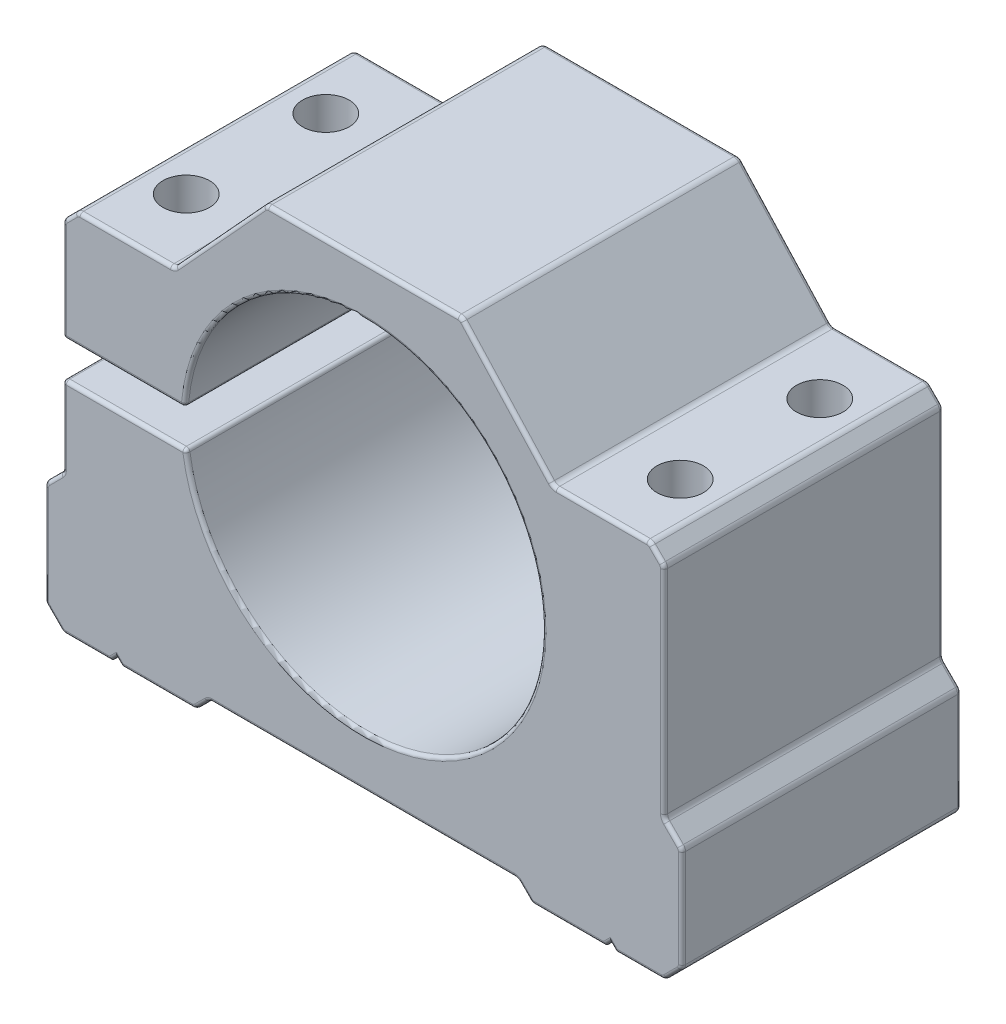
from build123d import *

# Parameters (mm, degrees)
EXTRUDE_1_DEPTH     = 19.5
SKETCH_2_R          = 3.25
CUT_EXTRUDE_1_DEPTH = 72.165300533
FILLET_1_R          = 1
FILLET_2_R          = 0.5


with BuildPart() as part:
    # Эскиз1 → Бобышка-Вытянуть1 (new, symmetric)
    with BuildSketch(Plane.XY):
        with BuildLine():
            Line((-21.5, -32), (21.5, -32))
            Line((21.5, -32), (23.5, -34))
            Line((23.5, -34), (33.75, -34))
            Line((33.75, -34), (34.5, -33.25))
            Line((34.5, -33.25), (35.25, -34))
            Line((35.25, -34), (42, -34))
            Line((42, -34), (44.5, -31.5))
            Line((44.5, -31.5), (44.5, -17))
            Line((44.5, -17), (42, -14.5))
            Line((42, -14.5), (42, 16))
            Line((42, 16), (40, 18))
            Line((40, 18), (26.5, 18))
            Line((26.5, 18), (13.671363564, 32))
            Line((13.671363564, 32), (-13.671363564, 32))
            Line((-13.671363564, 32), (-26.5, 18))
            Line((-26.5, 18), (-40, 18))
            Line((-40, 18), (-42, 16))
            Line((-42, 16), (-42, 1.75))
            Line((-42, 1.75), (-24.938674784, 1.75))
            ThreePointArc((-24.938674784, 1.75), (0.87553709, 24.984663992), (25, 0))
            ThreePointArc((25, 0), (1.62845845, -24.946906082), (-24.787849846, -3.25))
            Line((-24.787849846, -3.25), (-42, -3.25))
            Line((-42, -3.25), (-42, -14.5))
            Line((-42, -14.5), (-44.5, -17))
            Line((-44.5, -17), (-44.5, -31.5))
            Line((-44.5, -31.5), (-42, -34))
            Line((-42, -34), (-35.25, -34))
            Line((-35.25, -34), (-34.5, -33.25))
            Line((-34.5, -33.25), (-33.75, -34))
            Line((-33.75, -34), (-23.5, -34))
            Line((-23.5, -34), (-21.5, -32))
        make_face()
    extrude(amount=EXTRUDE_1_DEPTH, both=True)

    # Эскиз2 → Вырез-Вытянуть1 (cut, through all)
    with BuildSketch(Plane(origin=(0, 18, 0), x_dir=(1, 0, 0), z_dir=(0, 1, 0))):
        with Locations(Location((-34.5, -9.75, 0), (0, 0, 270))):
            Circle(SKETCH_2_R)
        with Locations(Location((-34.5, 9.75, 0), (0, 0, 270))):
            Circle(SKETCH_2_R)
        with Locations(Location((34.5, -9.75, 0), (0, 0, 270))):
            Circle(SKETCH_2_R)
        with Locations(Location((34.5, 9.75, 0), (0, 0, 270))):
            Circle(SKETCH_2_R)
    extrude(amount=-CUT_EXTRUDE_1_DEPTH, mode=Mode.SUBTRACT)

    # Скругление1
    fillet_1_edges = [part.edges().sort_by_distance(p)[0] for p in [
        (-42, 16, -9.75),
        (-40, 18, -9.75),
        (-26.5, 18, -9.75),
        (-13.671363564, 32, -9.75),
        (13.671363564, 32, -9.75),
        (26.5, 18, -9.75),
        (40, 18, -9.75),
        (42, 16, -9.75),
        (42, -14.5, -9.75),
        (44.5, -17, -9.75),
        (44.5, -31.5, -9.75),
        (42, -34, -9.75),
        (23.5, -34, -9.75),
        (21.5, -32, -9.75),
        (-21.5, -32, -9.75),
        (-23.5, -34, -9.75),
        (-42, -34, -9.75),
        (-44.5, -31.5, -9.75),
        (-44.5, -17, -9.75),
        (-42, -14.5, -9.75),
    ]]
    fillet(fillet_1_edges, radius=FILLET_1_R)

    # Скругление2
    fillet_2_edges = [part.edges().sort_by_distance(p)[0] for p in [
        (-42, 8.667893219, 19.5),
        (-33.469337392, 1.75, 19.5),
        (-41, 17, -19.5),
        (-33.262898484, 18, -19.5),
        (-20.085681782, 25, -19.5),
        (0, 32, -19.5),
        (20.085681782, 25, -19.5),
        (33.262898484, 18, -19.5),
        (41, 17, -19.5),
        (42, 0.75, -19.5),
        (43.25, -15.75, -19.5),
        (44.5, -24.25, -19.5),
        (43.25, -32.75, -19.5),
        (28.832106781, -34, -19.5),
        (22.5, -33, -19.5),
        (0, -32, -19.5),
        (-22.5, -33, -19.5),
        (-28.832106781, -34, -19.5),
        (-43.25, -32.75, -19.5),
        (-44.5, -24.25, -19.5),
        (-43.25, -15.75, -19.5),
        (-42, -8.667893219, -19.5),
        (-44.423879533, -17.03153013, -19.5),
        (-44.423879533, -31.46846987, -19.5),
        (-41.96846987, -33.923879533, -19.5),
        (-23.53153013, -33.923879533, -19.5),
        (23.53153013, -33.923879533, -19.5),
        (41.96846987, -33.923879533, -19.5),
        (44.423879533, -31.46846987, -19.5),
        (44.423879533, -17.03153013, -19.5),
        (41.923879533, 15.96846987, -19.5),
        (39.96846987, 17.923879533, -19.5),
        (13.634099723, 31.915311479, -19.5),
        (-13.634099723, 31.915311479, -19.5),
        (-39.96846987, 17.923879533, -19.5),
        (-41.923879533, 15.96846987, -19.5),
        (-41, 17, 19.5),
        (-42, -8.667893219, 19.5),
        (-43.25, -15.75, 19.5),
        (-44.5, -24.25, 19.5),
        (-43.25, -32.75, 19.5),
        (-28.832106781, -34, 19.5),
        (-22.5, -33, 19.5),
        (0, -32, 19.5),
        (22.5, -33, 19.5),
        (28.832106781, -34, 19.5),
        (43.25, -32.75, 19.5),
        (44.5, -24.25, 19.5),
        (43.25, -15.75, 19.5),
        (42, 0.75, 19.5),
        (41, 17, 19.5),
        (33.262898484, 18, 19.5),
        (20.085681782, 25, 19.5),
        (0, 32, 19.5),
        (-20.085681782, 25, 19.5),
        (-33.262898484, 18, 19.5),
        (-44.423879533, -17.03153013, 19.5),
        (-44.423879533, -31.46846987, 19.5),
        (-41.96846987, -33.923879533, 19.5),
        (-23.53153013, -33.923879533, 19.5),
        (23.53153013, -33.923879533, 19.5),
        (41.96846987, -33.923879533, 19.5),
        (44.423879533, -31.46846987, 19.5),
        (44.423879533, -17.03153013, 19.5),
        (41.923879533, 15.96846987, 19.5),
        (39.96846987, 17.923879533, 19.5),
        (13.634099723, 31.915311479, 19.5),
        (-13.634099723, 31.915311479, 19.5),
        (-39.96846987, 17.923879533, 19.5),
        (-41.923879533, 15.96846987, 19.5),
        (-26.537263841, 18.084688521, -19.5),
        (-26.537263841, 18.084688521, 19.5),
        (26.537263841, 18.084688521, -19.5),
        (26.537263841, 18.084688521, 19.5),
        (42.076120467, -14.46846987, -19.5),
        (42.076120467, -14.46846987, 19.5),
        (21.46846987, -32.076120467, -19.5),
        (21.46846987, -32.076120467, 19.5),
        (-21.46846987, -32.076120467, -19.5),
        (-21.46846987, -32.076120467, 19.5),
        (-42.076120467, -14.46846987, -19.5),
        (-42.076120467, -14.46846987, 19.5),
        (-33.469337392, 1.75, -19.5),
        (-38.417893219, -34, 19.5),
        (-42, 8.667893219, -19.5),
        (-34.875, -33.625, 19.5),
        (38.417893219, -34, -19.5),
        (34.875, -33.625, -19.5),
        (34.125, -33.625, -19.5),
        (-34.125, -33.625, 19.5),
        (-34.125, -33.625, -19.5),
        (-34.875, -33.625, -19.5),
        (-38.417893219, -34, -19.5),
        (-33.393924923, -3.25, -19.5),
        (0.87553709, 24.984663992, -19.5),
        (0.87553709, 24.984663992, 19.5),
        (-24.938674784, 1.75, 9.75),
        (-42, 1.75, 9.75),
        (-42, -3.25, 0),
        (-24.787849846, -3.25, 9.75),
        (34.125, -33.625, 19.5),
        (34.875, -33.625, 19.5),
        (38.417893219, -34, 19.5),
        (-33.393924923, -3.25, 19.5),
    ]]
    fillet(fillet_2_edges, radius=FILLET_2_R)


solid = part.part
